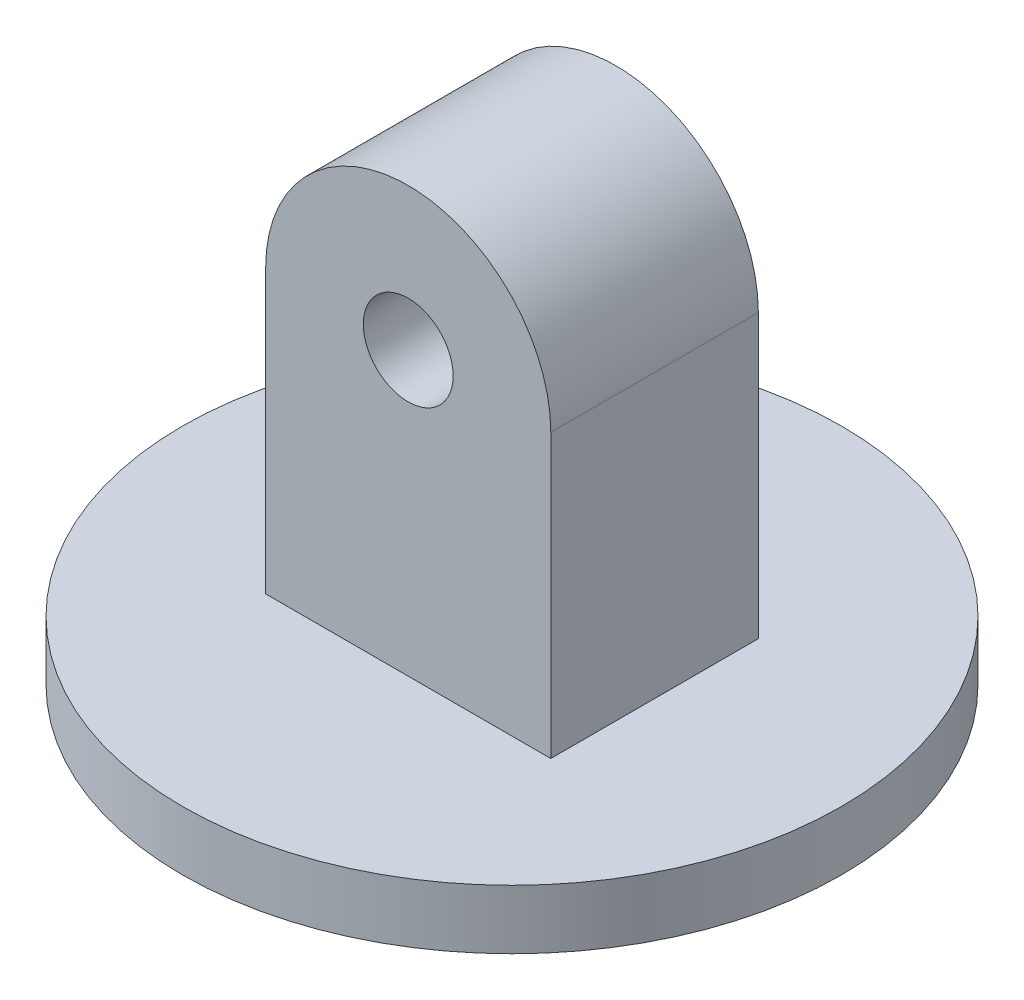
from build123d import *

# Parameters (mm, degrees)
SKETCH2_R           = 3.02870098
BOSS_EXTRUDE1_DEPTH = 14
SKETCH3_W           = 22.225
SKETCH3_H           = 4
SKETCH4_R           = 3.175
CUT_EXTRUDE1_DEPTH  = 4


with BuildPart() as part:
    # Sketch2 → Boss-Extrude1 (new body)
    with BuildSketch(Plane.XY):
        with BuildLine():
            Line((-9.616125613, -19.05), (9.616125613, -19.05))
            Line((9.616125613, -19.05), (9.616125613, 0))
            ThreePointArc((9.616125613, 0), (0, 9.616125613), (-9.616125613, 0))
            Line((-9.616125613, 0), (-9.616125613, -19.05))
        make_face()
        Circle(SKETCH2_R, mode=Mode.SUBTRACT)
    extrude(amount=BOSS_EXTRUDE1_DEPTH)

    # Sketch3 → Revolve1 (revolve)
    with BuildSketch(Plane(origin=(0, 0, 0), x_dir=(0, 0, -1), z_dir=(1, 0, 0))):
        with Locations((4.1125, -21.05)):
            Rectangle(SKETCH3_W, SKETCH3_H)
    revolve(axis=Axis((0, -23.05, 7), (0, 1, 0)))

    # Sketch4 → Cut-Extrude1 (cut)
    with BuildSketch(Plane(origin=(0, -23.05, 0), x_dir=(-1, 0, 0), z_dir=(0, -1, 0))):
        with Locations((0, -7)):
            Circle(SKETCH4_R)
    extrude(amount=-CUT_EXTRUDE1_DEPTH, mode=Mode.SUBTRACT)


solid = part.part
